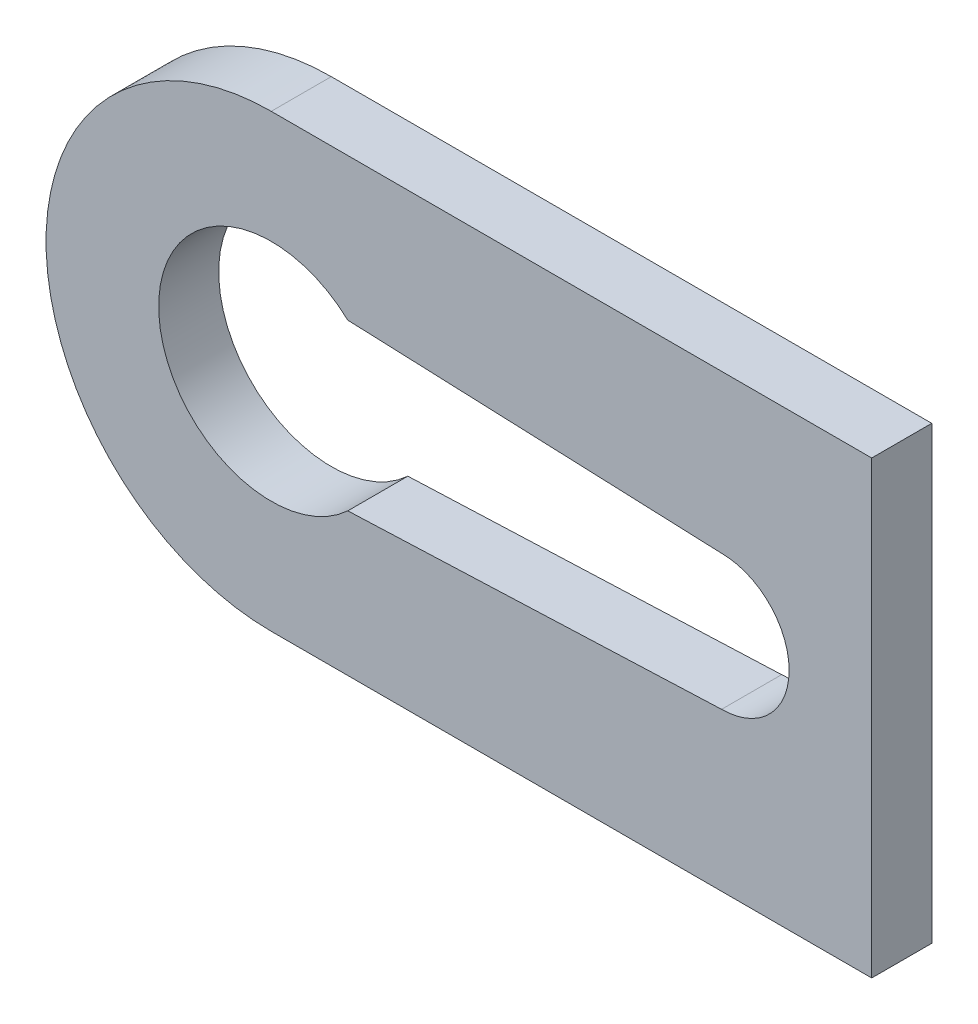
from build123d import *

# Parameters (mm, degrees)
BOSS_EXTRUDE1_DEPTH = 2


with BuildPart() as part:
    # Sketch1 → Boss-Extrude1 (new body)
    with BuildSketch(Plane.XY):
        with BuildLine():
            Line((5, 7.5), (-15, 7.5))
            ThreePointArc((-15, 7.5), (-22.5, 0), (-15, -7.5))
            Line((-15, -7.5), (5, -7.5))
            Line((5, -7.5), (5, 7.5))
        make_face()
        with BuildLine():
            ThreePointArc((-12.450490243, -2.75), (-18.75, 0), (-12.450490243, 2.75))
            Line((-12.450490243, 2.75), (0, 2.25))
            ThreePointArc((0, 2.25), (1.590990258, 1.590990258), (2.25, 0))
            ThreePointArc((2.25, 0), (1.590990258, -1.590990258), (0, -2.25))
            Line((0, -2.25), (-12.450490243, -2.75))
        make_face(mode=Mode.SUBTRACT)
    extrude(amount=BOSS_EXTRUDE1_DEPTH)


solid = part.part
